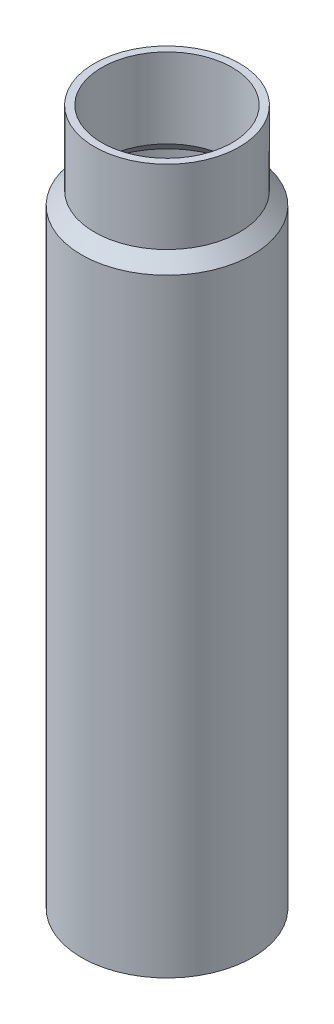
from build123d import *


with BuildPart() as part:
    # Sketch3 → Revolve1 (revolve)
    with BuildSketch(Plane.XY):
        Polygon((0, 0), (37.465, 0), (37.465, 266.7), (31.75, 272.415), (31.75, 304.8), (28.575, 304.8), (28.575, 269.875), (34.925, 263.525), (34.925, 3.175), (0, 3.175), align=None)
    revolve(axis=Axis((0, 0, 0), (0, 1, 0)))


solid = part.part
